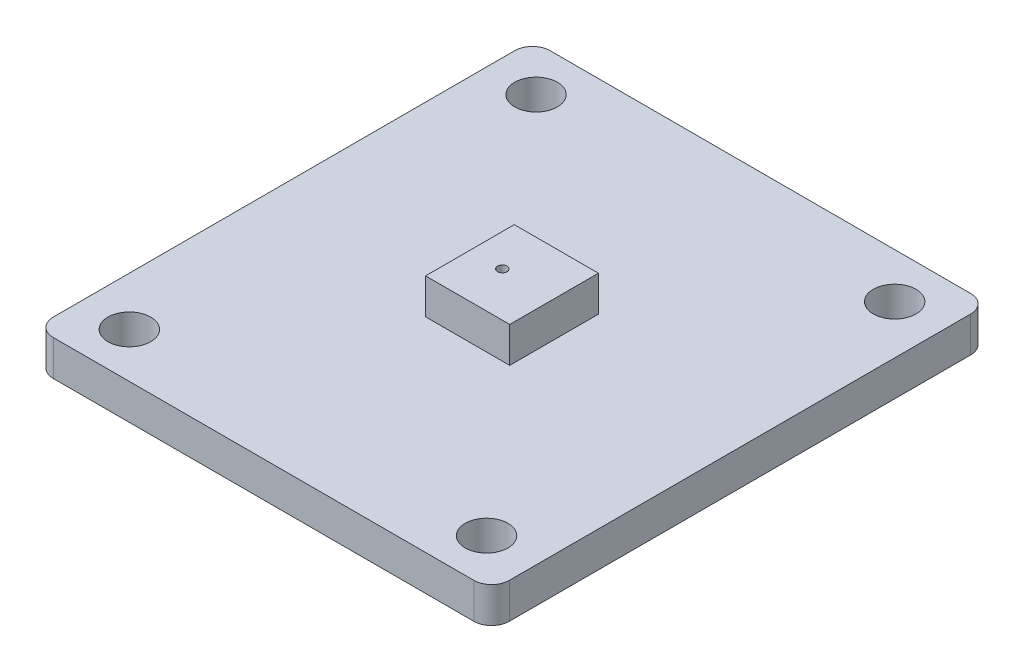
from build123d import *

# Parameters (mm, degrees)
SKETCH1_R           = 1.205
BOSS_EXTRUDE1_DEPTH = 2
SKETCH2_W           = 4.74
SKETCH2_H           = 5
SKETCH2_R           = 0.271758231
BOSS_EXTRUDE2_DEPTH = 4


with BuildPart() as part:
    # Sketch1 → Boss-Extrude1 (new body)
    with BuildSketch(Plane(origin=(0, 0, 0), x_dir=(1, 0, 0), z_dir=(0, 1, 0))):
        with BuildLine():
            Line((-11.85, 14), (11.85, 14))
            ThreePointArc((11.85, 14), (12.557106781, 13.707106781), (12.85, 13))
            Line((12.85, 13), (12.85, -13))
            ThreePointArc((12.85, -13), (12.557106781, -13.707106781), (11.85, -14))
            Line((11.85, -14), (-11.85, -14))
            ThreePointArc((-11.85, -14), (-12.557106781, -13.707106781), (-12.85, -13))
            Line((-12.85, -13), (-12.85, 13))
            ThreePointArc((-12.85, 13), (-12.557106781, 13.707106781), (-11.85, 14))
        make_face()
        with Locations((-10.105, 11.46)):
            Circle(SKETCH1_R, mode=Mode.SUBTRACT)
        with Locations((-10.105, -11.46)):
            Circle(SKETCH1_R, mode=Mode.SUBTRACT)
        with Locations((10.026555832, -11.46)):
            Circle(SKETCH1_R, mode=Mode.SUBTRACT)
        with Locations((10.105, 11.46)):
            Circle(SKETCH1_R, mode=Mode.SUBTRACT)
    extrude(amount=BOSS_EXTRUDE1_DEPTH)

    # Sketch2 → Boss-Extrude2 (add)
    with BuildSketch(Plane(origin=(0, 0, 0), x_dir=(1, 0, 0), z_dir=(0, 1, 0))):
        Rectangle(SKETCH2_W, SKETCH2_H)
        with Locations((-0.548413106, 0)):
            Circle(SKETCH2_R, mode=Mode.SUBTRACT)
    extrude(amount=BOSS_EXTRUDE2_DEPTH)


solid = part.part
